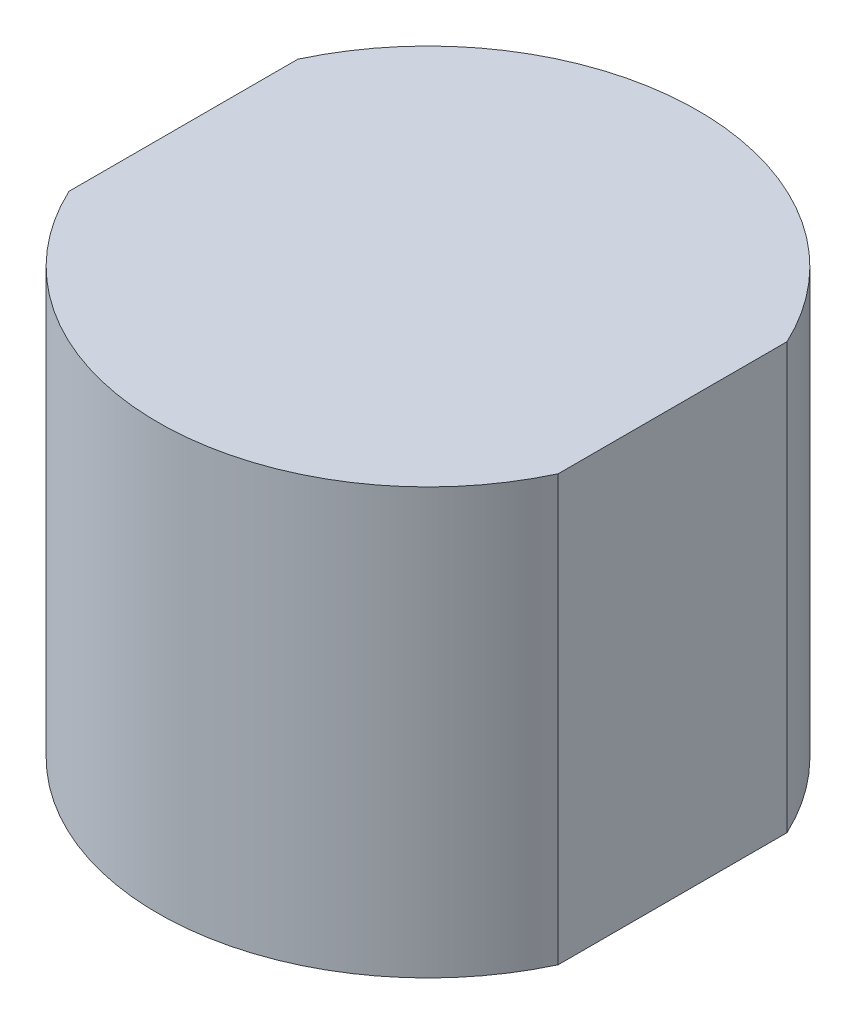
from build123d import *

# Parameters (mm, degrees)
BOSS_EXTRUDE1_DEPTH = 10


with BuildPart() as part:
    # Sketch1 → Boss-Extrude1 (new body)
    with BuildSketch(Plane(origin=(0, 0, 0), x_dir=(1, 0, 0), z_dir=(0, 1, 0))):
        with BuildLine():
            ThreePointArc((-5.752077885, -2.69), (0, -6.35), (5.752077885, -2.69))
            Line((5.752077885, -2.69), (5.752077885, 2.69))
            ThreePointArc((5.752077885, 2.69), (0, 6.35), (-5.752077885, 2.69))
            Line((-5.752077885, 2.69), (-5.752077885, -2.69))
        make_face()
    extrude(amount=BOSS_EXTRUDE1_DEPTH)


solid = part.part
